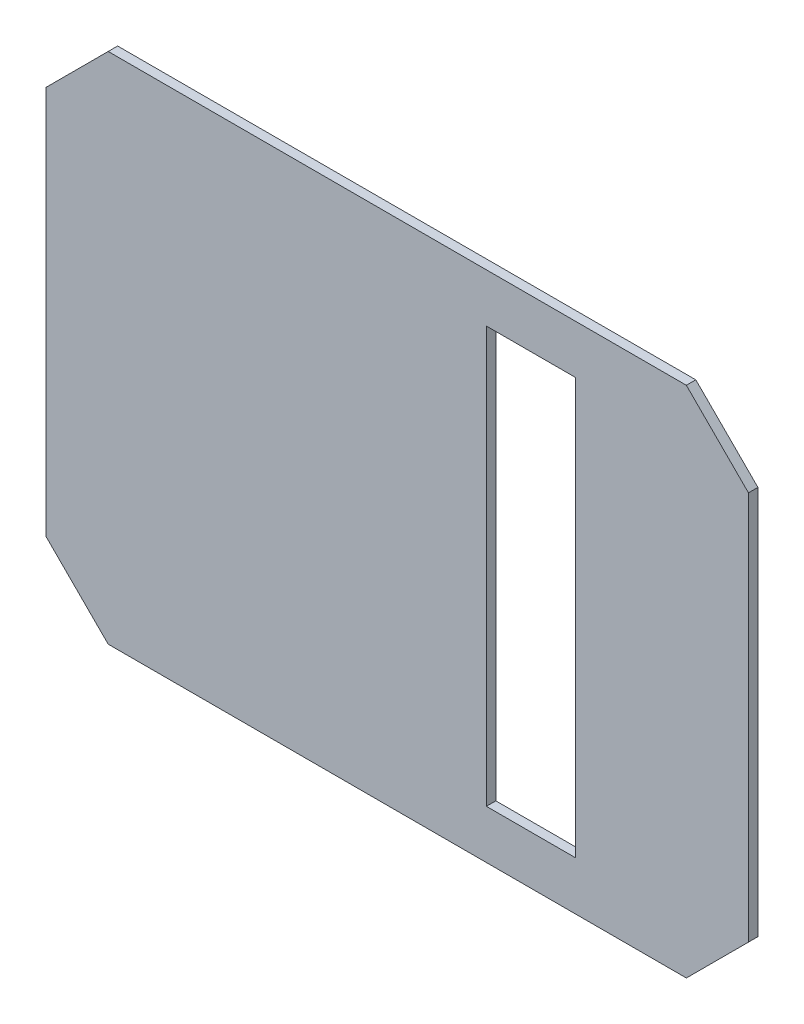
from build123d import *

# Parameters (mm, degrees)
BOSS_EXTRUDE1_DEPTH = 3.175
SKETCH5_W           = 30
SKETCH5_H           = 139.7
CUT_EXTRUDE7_DEPTH  = 3.175


with BuildPart() as part:
    # Sketch1 → Boss-Extrude1 (new body)
    with BuildSketch(Plane.XY):
        Polygon((97.092135624, -86.2), (-97.092135624, -86.2), (-117.95, -65.342135624), (-117.95, 65.342135624), (-97.092135624, 86.2), (97.092135624, 86.2), (117.95, 65.342135624), (117.95, -65.342135624), align=None)
    extrude(amount=BOSS_EXTRUDE1_DEPTH)

    # Sketch5 → Cut-Extrude7 (cut)
    with BuildSketch(Plane.XY.offset(3.175)):
        with Locations((44.925, 0)):
            Rectangle(SKETCH5_W, SKETCH5_H)
    extrude(amount=-CUT_EXTRUDE7_DEPTH, mode=Mode.SUBTRACT)


solid = part.part
